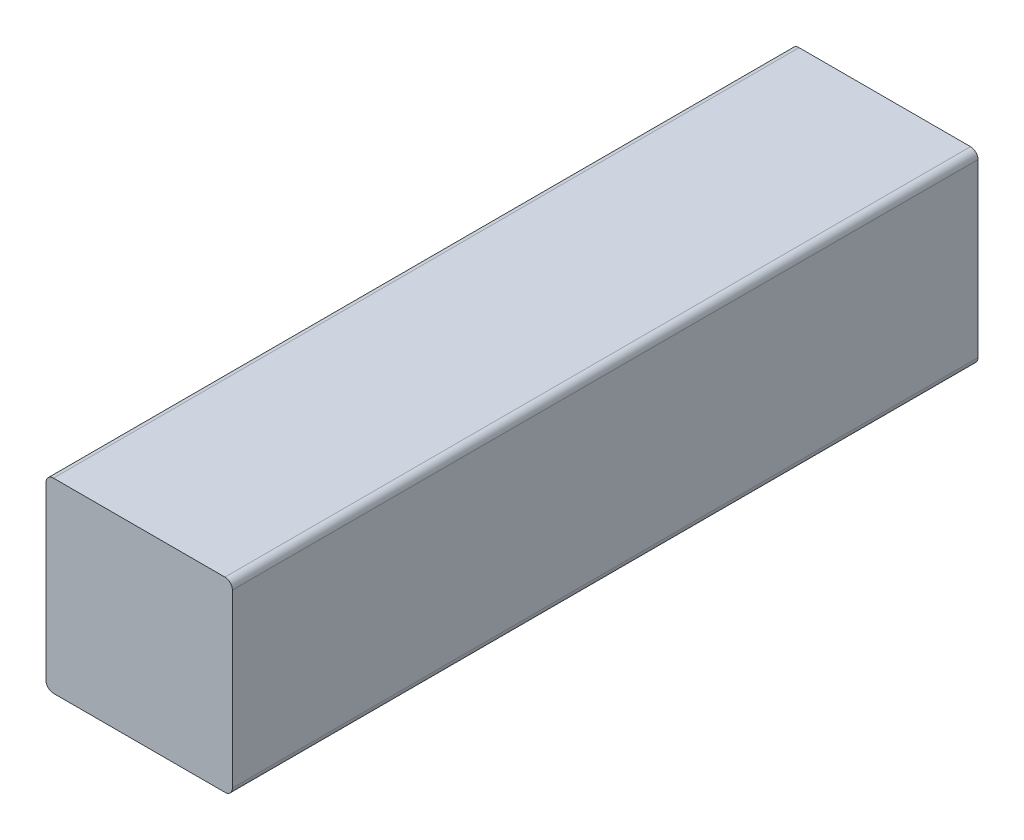
from build123d import *

# Parameters (mm, degrees)
BOSS_EXTRUDE1_START = -3.175
SKETCH4_W           = 25.4
SKETCH4_H           = 6.35
BOSS_EXTRUDE1_DEPTH = 6.35
FILLET1_R           = 0.254


with BuildPart() as part:
    # Sketch4 → Boss-Extrude1 (new body)
    with BuildSketch(Plane(origin=(0, 0, 0), x_dir=(0, 0, -1), z_dir=(1, 0, 0)).offset(BOSS_EXTRUDE1_START)):
        Rectangle(SKETCH4_W, SKETCH4_H)
    extrude(amount=BOSS_EXTRUDE1_DEPTH)

    # Fillet1
    fillet1_edges = [part.edges().sort_by_distance(p)[0] for p in [
        (3.175, 3.175, 0),
        (3.175, -3.175, 0),
        (-3.175, 3.175, 0),
        (-3.175, -3.175, 0),
    ]]
    fillet(fillet1_edges, radius=FILLET1_R)


solid = part.part
